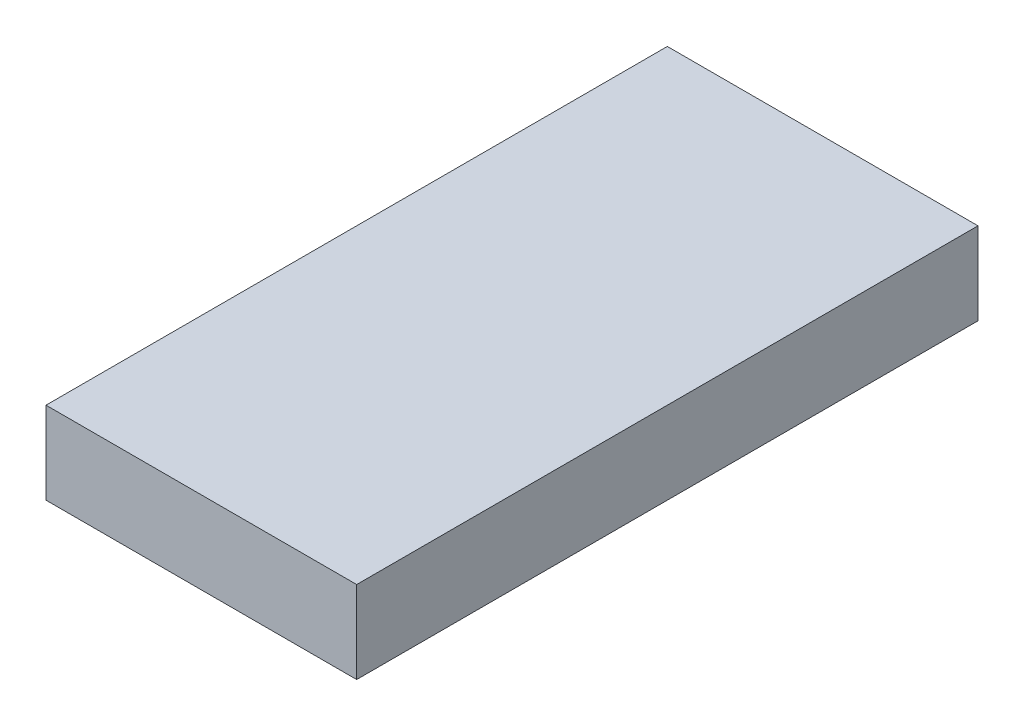
from build123d import *

# Parameters (mm, degrees)
SKETCH1_W      = 755
SKETCH1_H      = 755
EXTRUDE1_DEPTH = 100
SKETCH2_W      = 453.222713864
SKETCH2_H      = 819.883972468
EXTRUDE2_DEPTH = 101


with BuildPart() as part:
    # Sketch1 → Extrude1 (new body)
    with BuildSketch(Plane(origin=(0, 0, 0), x_dir=(1, 0, 0), z_dir=(0, 1, 0))):
        Rectangle(SKETCH1_W, SKETCH1_H)
    extrude(amount=EXTRUDE1_DEPTH)

    # Sketch2 → Extrude2 (cut, through all)
    with BuildSketch(Plane(origin=(0, 100, 0), x_dir=(1, 0, 0), z_dir=(0, 1, 0))):
        with Locations((-226.611356932, -13.882497542)):
            Rectangle(SKETCH2_W, SKETCH2_H)
    extrude(amount=-EXTRUDE2_DEPTH, mode=Mode.SUBTRACT)


solid = part.part
